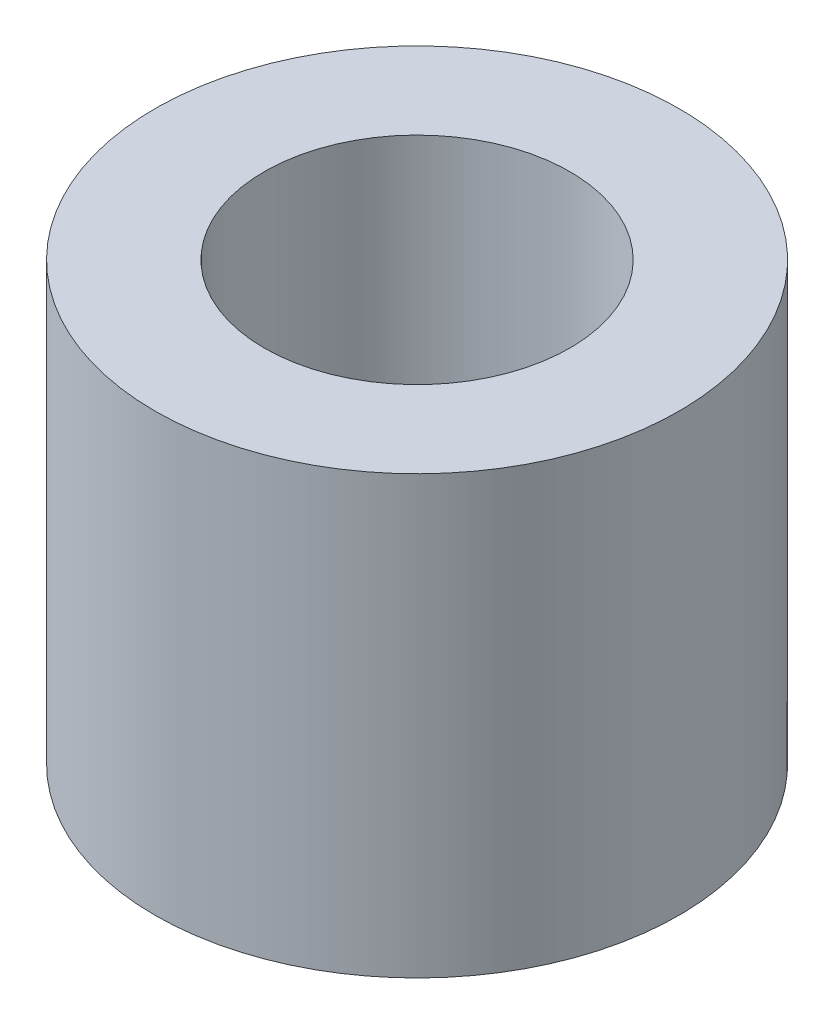
from build123d import *

# Parameters (mm, degrees)
SKETCH1_R           = 3
SKETCH1_R_2         = 1.75
BOSS_EXTRUDE1_DEPTH = 10
MOVE_FACE1_BY       = 5
MOVE_FACE2_BY       = 10


with BuildPart() as part:
    # Sketch1 → Boss-Extrude1 (new body)
    with BuildSketch(Plane(origin=(0, 0, 0), x_dir=(1, 0, 0), z_dir=(0, 1, 0))):
        with Locations(Location((0, 0, 0), (0, 0, 270))):
            Circle(SKETCH1_R)
        with Locations(Location((0, 0, 0), (0, 0, 270))):
            Circle(SKETCH1_R_2, mode=Mode.SUBTRACT)
    extrude(amount=BOSS_EXTRUDE1_DEPTH)

    # Move Face1: a face moved outward by 5.0
    extrude(part.faces().sort_by_distance((0, 0, 2.4))[0], amount=MOVE_FACE1_BY, dir=(0, -1, 0))

    # Move Face2: a face moved inward by 10.0
    extrude(part.faces().sort_by_distance((0, -5, 2.4))[0], amount=MOVE_FACE2_BY, dir=(0, 1, 0), mode=Mode.SUBTRACT)


solid = part.part
